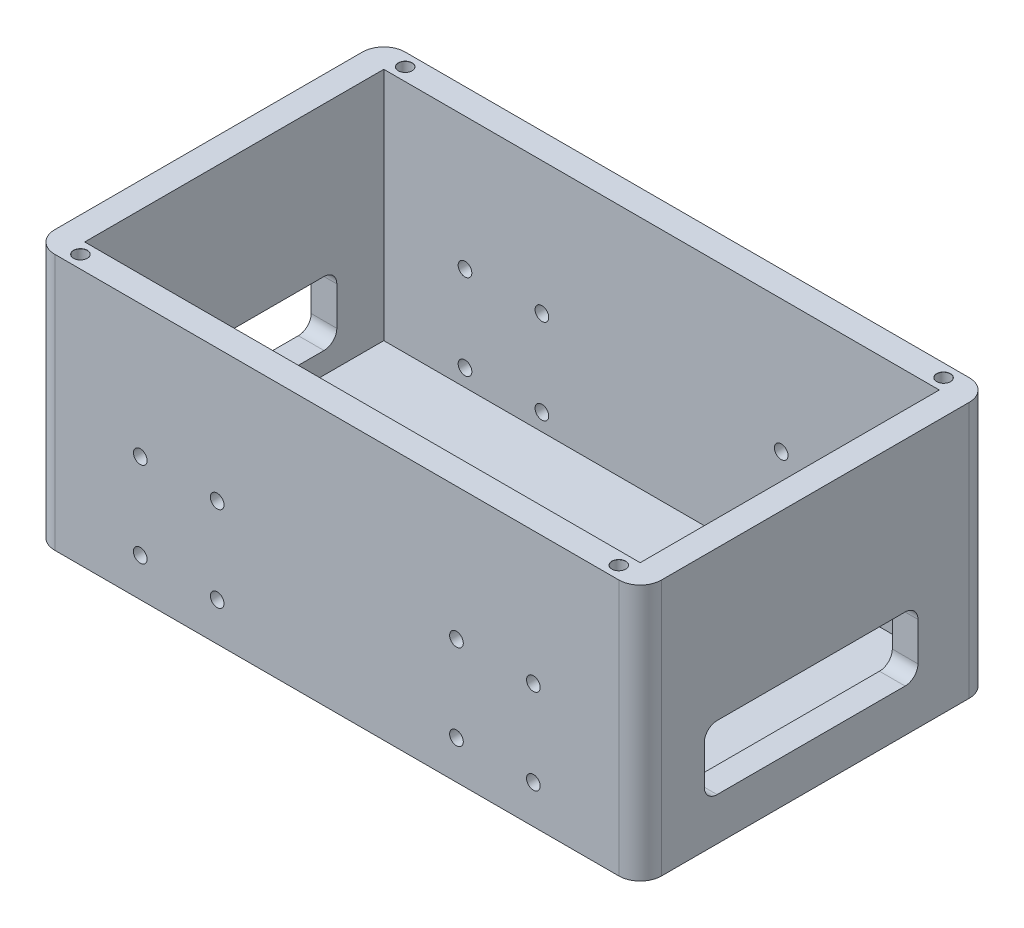
from build123d import *

# Parameters (mm, degrees)
SKETCH1_W                      = 142
SKETCH1_H                      = 82
BOSS_EXTRUDE1_DEPTH            = 60
SKETCH2_W                      = 130
SKETCH2_H                      = 70
CUT_EXTRUDE1_DEPTH             = 55
M3_CLEARANCE_HOLE1_D           = 3.2
M3_CLEARANCE_HOLE1_DEPTH       = 5
M3_CLEARANCE_HOLE1_CSINK_D     = 3.25
M3_CLEARANCE_HOLE1_CSINK_ANGLE = 90
M3_CLEARANCE_HOLE1_TIP         = 0.96137699
FILLET1_R                      = 5
SKETCH9_W                      = 50
SKETCH9_H                      = 15
CUT_EXTRUDE4_DEPTH             = 143
FILLET2_R                      = 3
M3_CLEARANCE_HOLE2_D           = 3.2
M3_CLEARANCE_HOLE2_CSINK_D     = 3.25
M3_CLEARANCE_HOLE2_CSINK_ANGLE = 90
M3_CLEARANCE_HOLE3_D           = 3.2
M3_CLEARANCE_HOLE3_CSINK_D     = 3.25
M3_CLEARANCE_HOLE3_CSINK_ANGLE = 90


with BuildPart() as part:
    # Sketch1 → Boss-Extrude1 (new body)
    with BuildSketch(Plane(origin=(0, 0, 0), x_dir=(1, 0, 0), z_dir=(0, 1, 0))):
        with Locations((71, -41)):
            Rectangle(SKETCH1_W, SKETCH1_H)
    extrude(amount=BOSS_EXTRUDE1_DEPTH)

    # Sketch2 → Cut-Extrude1 (cut)
    with BuildSketch(Plane(origin=(0, 60, 0), x_dir=(1, 0, 0), z_dir=(0, 1, 0))):
        with Locations((71, -41)):
            Rectangle(SKETCH2_W, SKETCH2_H)
    extrude(amount=-CUT_EXTRUDE1_DEPTH, mode=Mode.SUBTRACT)

    # M3 Clearance Hole1
    with Locations(Plane(origin=(0, 5, 0), x_dir=(1, 0, 0), z_dir=(0, 1, 0))):
        with Locations((118.5, -17), (120, -65), (67.5, -32), (67.5, -60)):
            CounterSinkHole(M3_CLEARANCE_HOLE1_D / 2, M3_CLEARANCE_HOLE1_CSINK_D / 2, depth=M3_CLEARANCE_HOLE1_DEPTH, counter_sink_angle=M3_CLEARANCE_HOLE1_CSINK_ANGLE)
            with Locations((0, 0, -(M3_CLEARANCE_HOLE1_DEPTH + M3_CLEARANCE_HOLE1_TIP / 2))):  # 118° drill point
                Cone(0, M3_CLEARANCE_HOLE1_D / 2, M3_CLEARANCE_HOLE1_TIP, mode=Mode.SUBTRACT)

    # Fillet1
    fillet1_edges = [part.edges().sort_by_distance(p)[0] for p in [
        (0, 30, 82),
        (0, 30, 0),
        (142, 30, 0),
        (142, 30, 82),
    ]]
    fillet(fillet1_edges, radius=FILLET1_R)

    # Sketch9 → Cut-Extrude4 (cut, through all)
    with BuildSketch(Plane(origin=(142, 0, 0), x_dir=(0, 0, -1), z_dir=(1, 0, 0))):
        with Locations((-42, 17.5)):
            Rectangle(SKETCH9_W, SKETCH9_H)
    extrude(amount=-CUT_EXTRUDE4_DEPTH, mode=Mode.SUBTRACT)

    # Fillet2
    fillet2_edges = [part.edges().sort_by_distance(p)[0] for p in [
        (139, 10, 17),
        (139, 10, 67),
        (139, 25, 67),
        (139, 25, 17),
        (3, 10, 17),
        (3, 10, 67),
        (3, 25, 67),
        (3, 25, 17),
    ]]
    fillet(fillet2_edges, radius=FILLET2_R)

    # M3 Clearance Hole2 (through all)
    with Locations(Plane(origin=(0, 60, 0), x_dir=(1, 0, 0), z_dir=(0, 1, 0))):
        with Locations((8, -3), (8, -79), (134, -79), (134, -3)):
            CounterSinkHole(M3_CLEARANCE_HOLE2_D / 2, M3_CLEARANCE_HOLE2_CSINK_D / 2, counter_sink_angle=M3_CLEARANCE_HOLE2_CSINK_ANGLE)

    # M3 Clearance Hole3 (through all)
    with Locations(Plane(origin=(0, 0, 0), x_dir=(-1, 0, 0), z_dir=(0, 0, -1))):
        with Locations((-117, 29), (-99, 29), (-117, 9), (-99, 9), (-25, 9), (-43, 9), (-43, 29), (-25, 29)):
            CounterSinkHole(M3_CLEARANCE_HOLE3_D / 2, M3_CLEARANCE_HOLE3_CSINK_D / 2, counter_sink_angle=M3_CLEARANCE_HOLE3_CSINK_ANGLE)


solid = part.part
